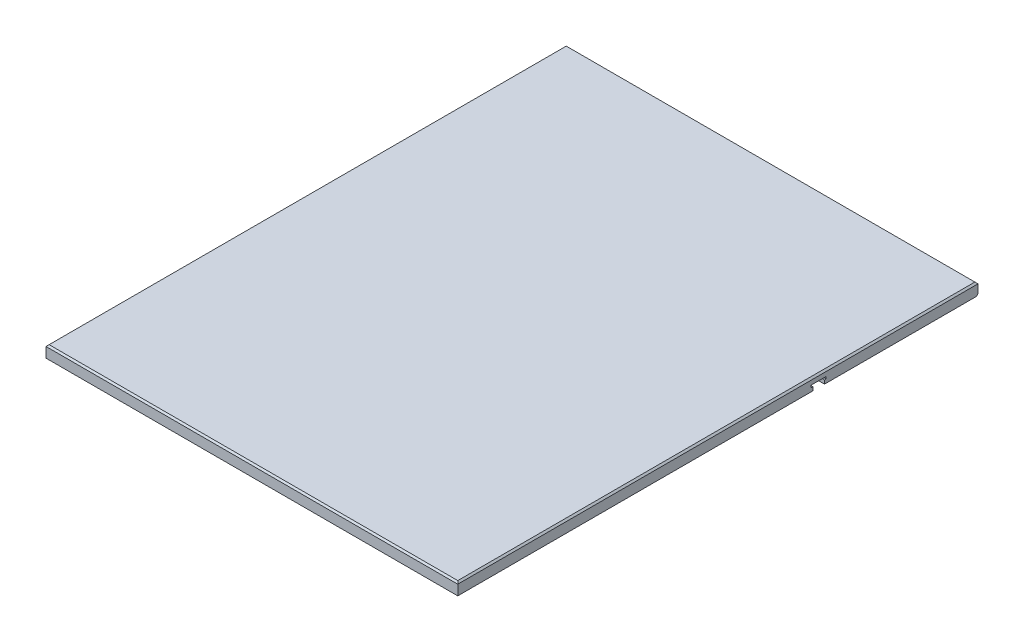
from build123d import *

# Parameters (mm, degrees)
SKETCH1_W           = 669.8488
SKETCH1_H           = 846.328
BOSS_EXTRUDE1_DEPTH = 19.05
CHAMFER1_SIZE       = 2.54
CHAMFER2_SIZE       = 2.54
CUT_EXTRUDE2_DEPTH  = 670.8488


with BuildPart() as part:
    # Sketch1 → Boss-Extrude1 (new body)
    with BuildSketch(Plane(origin=(0, 0, 0), x_dir=(1, 0, 0), z_dir=(0, 1, 0))):
        with Locations((334.9244, 423.164)):
            Rectangle(SKETCH1_W, SKETCH1_H)
    extrude(amount=BOSS_EXTRUDE1_DEPTH)

    # Chamfer1
    chamfer1_edges = [part.edges().sort_by_distance(p)[0] for p in [
        (669.8488, 19.05, -423.164),
        (334.9244, 19.05, -846.328),
        (0, 19.05, -423.164),
        (334.9244, 19.05, 0),
    ]]
    chamfer(chamfer1_edges, length=CHAMFER1_SIZE)

    # Chamfer2
    chamfer2_edges = [part.edges().sort_by_distance(p)[0] for p in [
        (334.9244, 0, -846.328),
    ]]
    chamfer(chamfer2_edges, length=CHAMFER2_SIZE)

    # Sketch3 → Cut-Extrude2 (cut, through all)
    with BuildSketch(Plane.ZY):
        Polygon((-596.63076, 5.97535), (-596.63076, 0), (-577.58076, 0), (-577.58076, 5.97535), (-574.91376, 5.97535), (-574.91376, 9.53135), (-599.29776, 9.53135), (-599.29776, 5.97535), align=None)
    extrude(amount=-CUT_EXTRUDE2_DEPTH, mode=Mode.SUBTRACT)


solid = part.part
